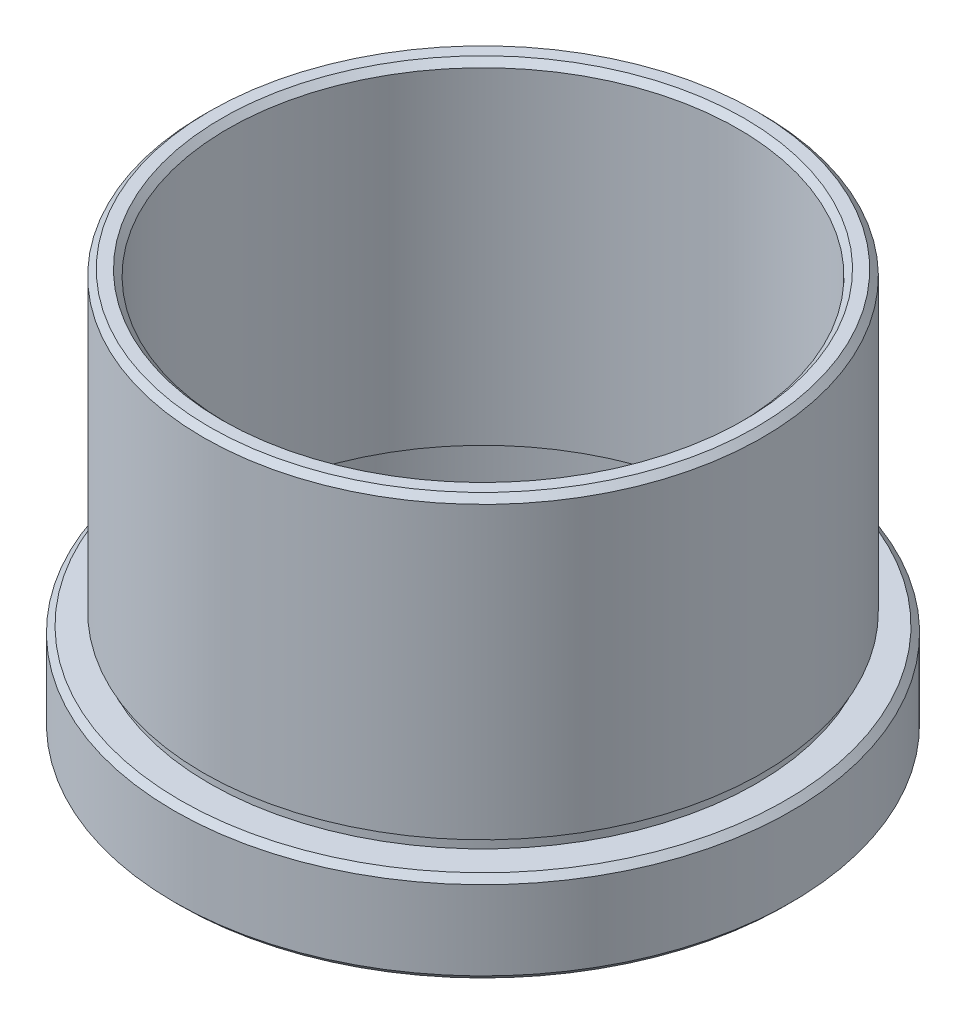
from build123d import *


with BuildPart() as part:
    # 草图1 → 旋转2 (revolve)
    with BuildSketch(Plane.XY, mode=Mode.PRIVATE) as revolve_2_sk:
        Polygon((21.5, 27.042854175), (22.5, 27.042854175), (23, 26.542854175), (23, 2.642854175), (22.5, 2.642854175), (22.5, 1.642854175), (24.9, 1.642854175), (25.4, 1.142854175), (25.4, -5.357145825), (24.9, -5.857145825), (24.5, -5.857145825), (24, -5.357145825), (24, -1.357145825), (24.1, -1.357145825), (24.1, -0.357145825), (21, -0.357145825), (21, 26.542854175), align=None)
    revolve(revolve_2_sk.sketch.rotate(Axis((0, 44.598597745, 0), (0, -1, 0)), 90), axis=Axis((0, 44.598597745, 0), (0, -1, 0)))  # turned: the seam where the file's is


solid = part.part
